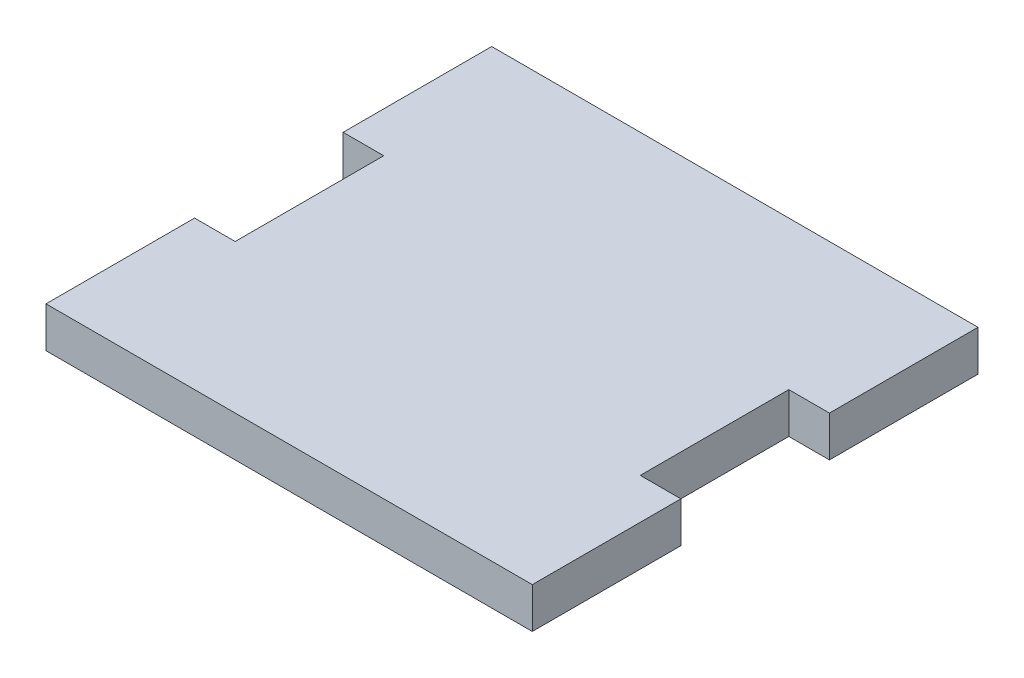
from build123d import *

# Parameters (mm, degrees)
BOSS_EXTRUDE1_DEPTH = 4.1


with BuildPart() as part:
    # Sketch1 → Boss-Extrude1 (new body)
    with BuildSketch(Plane(origin=(0, 0, 0), x_dir=(1, 0, 0), z_dir=(0, 1, 0))):
        Polygon((4.1, 0), (0, 0), (0, 15), (49.1, 15), (49.1, 0), (45, 0), (45, -15), (49.1, -15), (49.1, -30), (0, -30), (0, -15), (4.1, -15), align=None)
    extrude(amount=BOSS_EXTRUDE1_DEPTH)


solid = part.part
